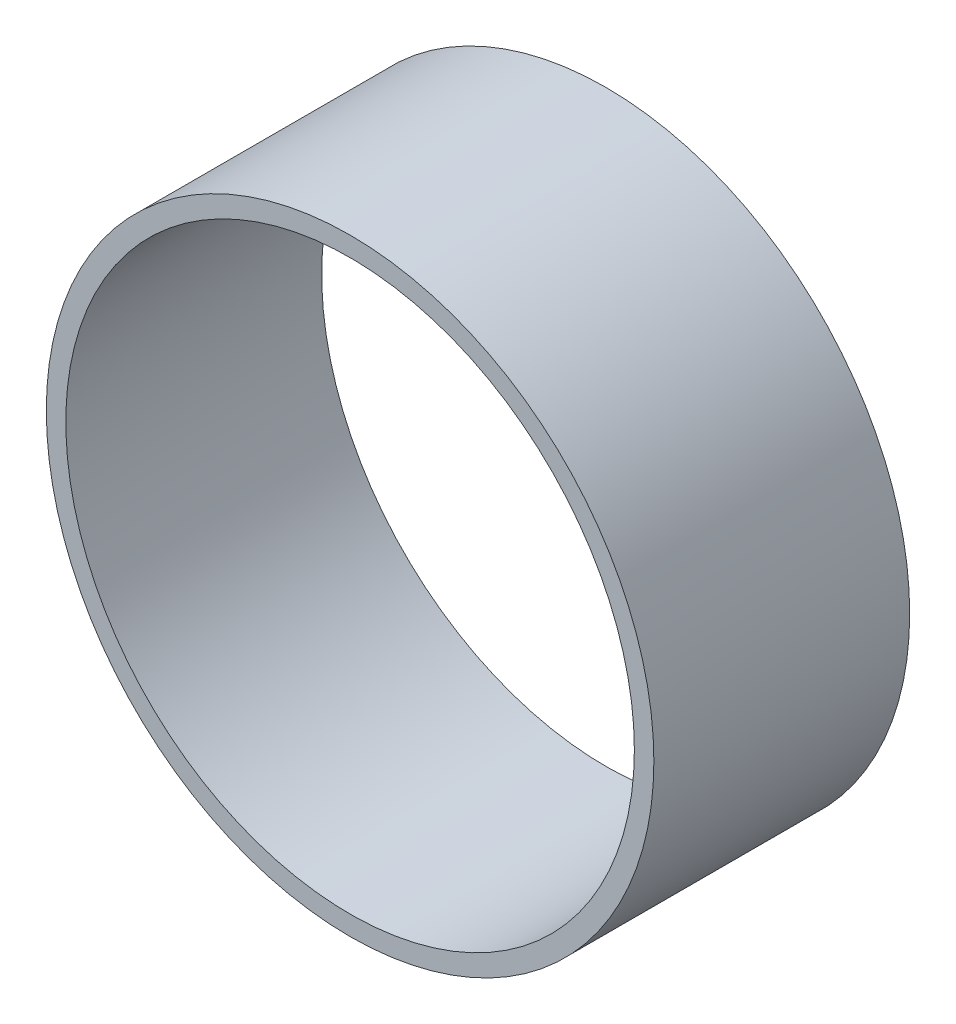
from build123d import *

# Parameters (mm, degrees)
SKETCH1_R           = 23.75
SKETCH1_R_2         = 22.225
BOSS_EXTRUDE1_DEPTH = 20


with BuildPart() as part:
    # Sketch1 → Boss-Extrude1 (new body)
    with BuildSketch(Plane.XY):
        Circle(SKETCH1_R)
        Circle(SKETCH1_R_2, mode=Mode.SUBTRACT)
    extrude(amount=BOSS_EXTRUDE1_DEPTH)


solid = part.part
